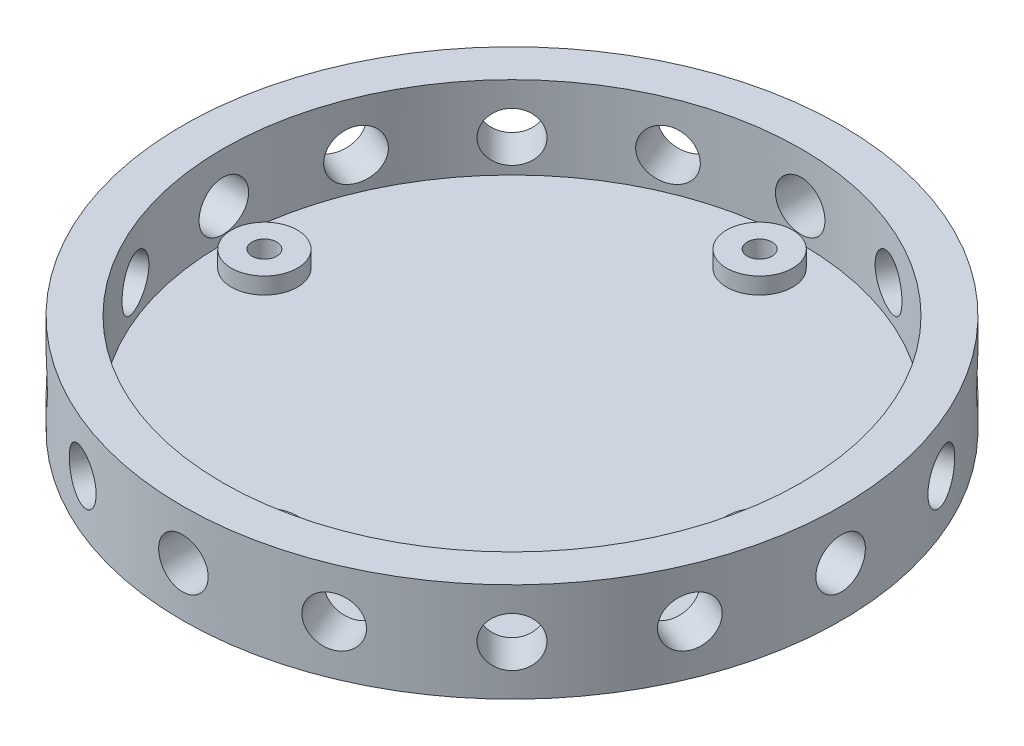
from build123d import *

# Parameters (mm, degrees)
SKETCH1_R           = 63.373
BOSS_EXTRUDE1_DEPTH = 3.175
SKETCH2_R           = 63.373
SKETCH2_R_2         = 55.626
BOSS_EXTRUDE2_DEPTH = 15.875
SKETCH9_R           = 4.7625
CUT_EXTRUDE2_DEPTH  = 64.373
CIRPATTERN5_COUNT   = 16
SKETCH4_R           = 6.35
SKETCH4_R_2         = 2.38125
BOSS_EXTRUDE4_DEPTH = 3.175
CIRPATTERN1_COUNT   = 4
SKETCH8_R           = 0.029426367
SKETCH8_R_2         = 2.38125
CUT_EXTRUDE1_DEPTH  = 20.0500001
CIRPATTERN3_COUNT   = 4


with BuildPart() as part:
    # Sketch1 → Boss-Extrude1 (new body)
    with BuildSketch(Plane(origin=(0, 0, 0), x_dir=(1, 0, 0), z_dir=(0, 1, 0))):
        Circle(SKETCH1_R)
    extrude(amount=BOSS_EXTRUDE1_DEPTH)

    # Sketch2 → Boss-Extrude2 (add)
    with BuildSketch(Plane(origin=(0, 3.175, 0), x_dir=(1, 0, 0), z_dir=(0, 1, 0))):
        Circle(SKETCH2_R)
        Circle(SKETCH2_R_2, mode=Mode.SUBTRACT)
    extrude(amount=BOSS_EXTRUDE2_DEPTH)

    # Sketch9 → Cut-Extrude2 (cut, through all)
    with BuildSketch(Plane.XY):
        with Locations((0, 9.525)):
            Circle(SKETCH9_R)
    cut_extrude2 = extrude(amount=-CUT_EXTRUDE2_DEPTH, mode=Mode.SUBTRACT)

    # CirPattern5: Cut-Extrude2 ×16 about axis
    cirpattern5_axis = Axis((0, 19.05, 0), (0, -1, 0))
    for i in range(1, CIRPATTERN5_COUNT):
        add(cut_extrude2.rotate(cirpattern5_axis, i * 360 / CIRPATTERN5_COUNT), mode=Mode.SUBTRACT)

    # Sketch4 → Boss-Extrude4 (add)
    with BuildSketch(Plane(origin=(0, 3.175, 0), x_dir=(1, 0, 0), z_dir=(0, 1, 0))):
        with Locations((-47.625, 0)):
            Circle(SKETCH4_R)
        with Locations((-47.625, 0)):
            Circle(SKETCH4_R_2, mode=Mode.SUBTRACT)
    boss_extrude4 = extrude(amount=BOSS_EXTRUDE4_DEPTH)

    # CirPattern1: Boss-Extrude4 ×4 about axis
    cirpattern1_axis = Axis((0, 0, 0), (0, 1, 0))
    for i in range(1, CIRPATTERN1_COUNT):
        add(boss_extrude4.rotate(cirpattern1_axis, i * 360 / CIRPATTERN1_COUNT))

    # Sketch8 → Cut-Extrude1 (cut, through all)
    with BuildSketch(Plane(origin=(0, 19.05, 0), x_dir=(1, 0, 0), z_dir=(0, 1, 0))):
        with Locations((-57.030443775, -0.834327162)):
            Circle(SKETCH8_R)
        with Locations((-47.625, 0)):
            Circle(SKETCH8_R_2)
    cut_extrude1 = extrude(amount=-CUT_EXTRUDE1_DEPTH, mode=Mode.SUBTRACT)

    # CirPattern3: Cut-Extrude1 ×4 about axis
    cirpattern3_axis = Axis((0, 0, 0), (0, 1, 0))
    for i in range(1, CIRPATTERN3_COUNT):
        add(cut_extrude1.rotate(cirpattern3_axis, i * 360 / CIRPATTERN3_COUNT), mode=Mode.SUBTRACT)


solid = part.part
